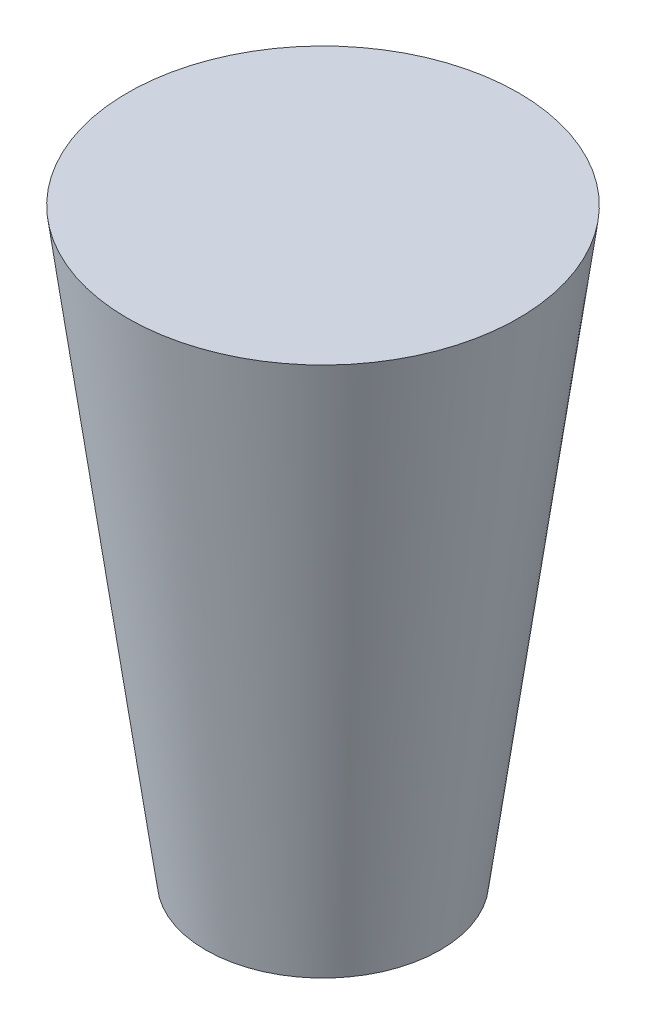
from build123d import *


with BuildPart() as part:
    # Esquisse1 → Révolution1 (revolve)
    with BuildSketch(Plane.XY):
        Polygon((0, -50), (-30, -50), (-50, 100), (0, 100), align=None)
    revolve(axis=Axis((0, 112.000741398, 0), (0, -1, 0)))


solid = part.part
